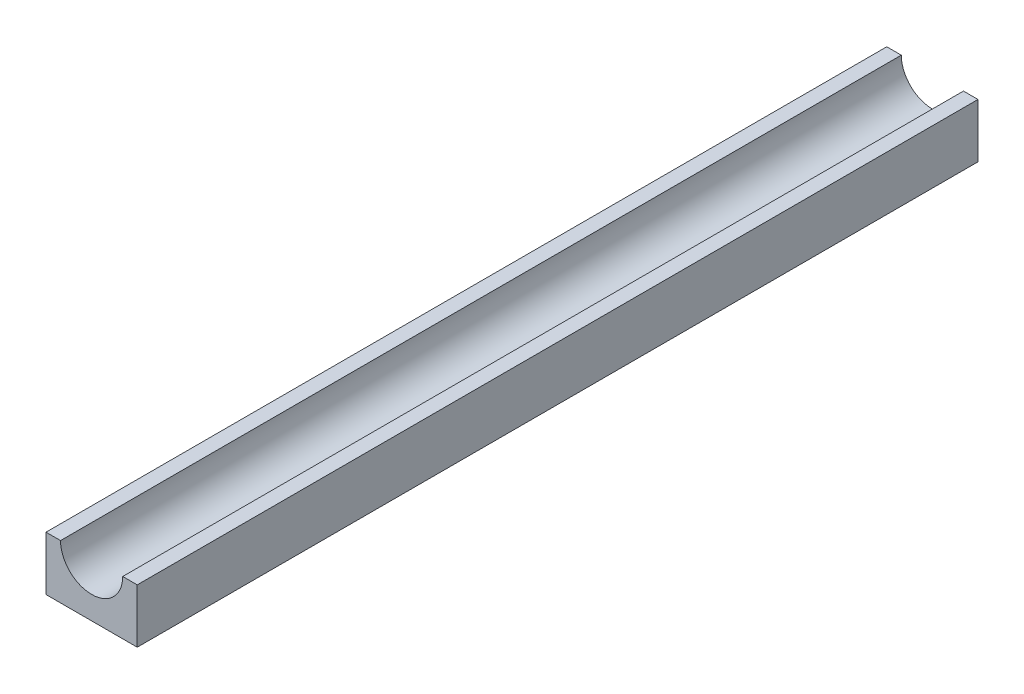
from build123d import *

# Parameters (mm, degrees)
BOSS_EXTRUDE1_DEPTH = 220


with BuildPart() as part:
    # Sketch1 → Boss-Extrude1 (new body)
    with BuildSketch(Plane.XY):
        with BuildLine():
            Line((8.1375, 7.06875), (11.9375, 7.06875))
            Line((11.9375, 7.06875), (11.9375, -7.06875))
            Line((11.9375, -7.06875), (-11.9375, -7.06875))
            Line((-11.9375, -7.06875), (-11.9375, 7.06875))
            Line((-11.9375, 7.06875), (-8.1375, 7.06875))
            ThreePointArc((-8.1375, 7.06875), (0, -1.06875), (8.1375, 7.06875))
        make_face()
    extrude(amount=BOSS_EXTRUDE1_DEPTH)


solid = part.part
